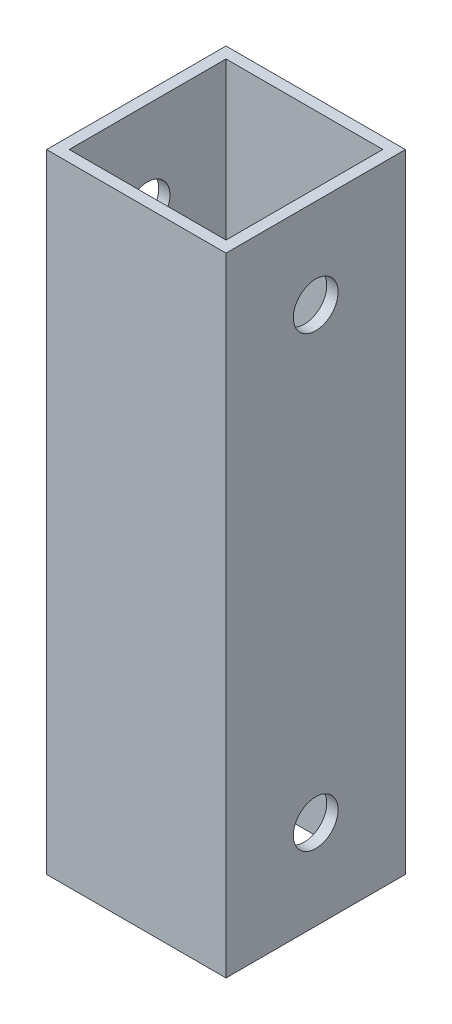
from build123d import *

# Parameters (mm, degrees)
SKETCH1_W           = 50.8
SKETCH1_H           = 50.8
SKETCH1_W_2         = 44.416753927
SKETCH1_H_2         = 44.416753927
BOSS_EXTRUDE1_DEPTH = 177.8
SKETCH2_R           = 6.35
CUT_EXTRUDE1_DEPTH  = 51.8


with BuildPart() as part:
    # Sketch1 → Boss-Extrude1 (new body)
    with BuildSketch(Plane(origin=(0, 0, 0), x_dir=(1, 0, 0), z_dir=(0, 1, 0))):
        Rectangle(SKETCH1_W, SKETCH1_H)
        with Locations((-0.016623037, 0.016623037)):
            Rectangle(SKETCH1_W_2, SKETCH1_H_2, mode=Mode.SUBTRACT)
    extrude(amount=BOSS_EXTRUDE1_DEPTH)

    # Sketch2 → Cut-Extrude1 (cut, through all)
    with BuildSketch(Plane.ZY.offset(25.4)):
        with Locations((0, 25.4)):
            Circle(SKETCH2_R)
        with Locations((0, 152.4)):
            Circle(SKETCH2_R)
    extrude(amount=-CUT_EXTRUDE1_DEPTH, mode=Mode.SUBTRACT)


solid = part.part
